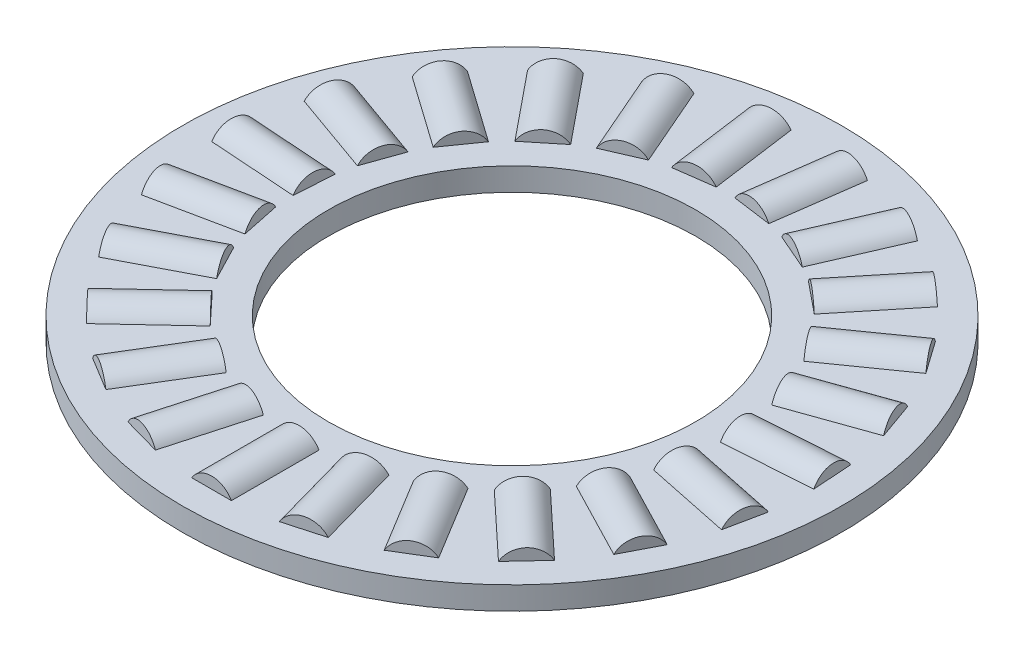
from build123d import *

# Parameters (mm, degrees)
SKETCH5_W         = 6.3246
SKETCH5_H         = 0.9921875
SKETCH3_W         = 3.79476
SKETCH3_H         = 0.9921875
SKETCH2_W         = 3.79476
SKETCH2_H         = 0.9921875
CIRPATTERN1_COUNT = 23
CIRPATTERN1_ANGLE = 344.347826087
CIRPATTERN2_COUNT = 23


with BuildPart() as part:
    # Sketch5 → Revolve3 (revolve)
    with BuildSketch(Plane(origin=(0, 0, 0), x_dir=(0, 0, -1), z_dir=(1, 0, 0))):
        with Locations((-11.1252, 0)):
            Rectangle(SKETCH5_W, SKETCH5_H)
    revolve(axis=Axis((0, -0.9921875, 0), (0, 1, 0)))

    # Sketch3 → Cut-Revolve1 (revolve, cut)
    with BuildSketch(Plane(origin=(0, 0, 0), x_dir=(0, 0, -1), z_dir=(1, 0, 0))):
        with Locations((-11.1252, 0.49609375)):
            Rectangle(SKETCH3_W, SKETCH3_H)
    cut_revolve1 = revolve(axis=Axis((0, 0, 13.02258), (0, 0, -1)), mode=Mode.SUBTRACT)

    # CirPattern2: Cut-Revolve1 ×23 about axis
    cirpattern2_axis = Axis((0, 0.9921875, 0), (0, -1, 0))
    for i in range(1, CIRPATTERN2_COUNT):
        add(cut_revolve1.rotate(cirpattern2_axis, i * 360 / CIRPATTERN2_COUNT), mode=Mode.SUBTRACT)


with BuildPart() as body_2:
    # Sketch2 → Revolve2 (revolve)
    with BuildSketch(Plane(origin=(0, 0, 0), x_dir=(0, 0, -1), z_dir=(1, 0, 0))):
        with Locations((-11.1252, 0.49609375)):
            Rectangle(SKETCH2_W, SKETCH2_H)
    revolve(axis=Axis((0, 0, 13.02258), (0, 0, -1)))


with BuildPart() as cirpattern1_1:
    # CirPattern1: pattern copy
    add(body_2.part.rotate(Axis((0, 0.9921875, 0), (0, -1, 0)), 1 * CIRPATTERN1_ANGLE / (CIRPATTERN1_COUNT - 1)))


with BuildPart() as cirpattern1_2:
    # CirPattern1: pattern copy
    add(body_2.part.rotate(Axis((0, 0.9921875, 0), (0, -1, 0)), 2 * CIRPATTERN1_ANGLE / (CIRPATTERN1_COUNT - 1)))


with BuildPart() as cirpattern1_3:
    # CirPattern1: pattern copy
    add(body_2.part.rotate(Axis((0, 0.9921875, 0), (0, -1, 0)), 3 * CIRPATTERN1_ANGLE / (CIRPATTERN1_COUNT - 1)))


with BuildPart() as cirpattern1_4:
    # CirPattern1: pattern copy
    add(body_2.part.rotate(Axis((0, 0.9921875, 0), (0, -1, 0)), 4 * CIRPATTERN1_ANGLE / (CIRPATTERN1_COUNT - 1)))


with BuildPart() as cirpattern1_5:
    # CirPattern1: pattern copy
    add(body_2.part.rotate(Axis((0, 0.9921875, 0), (0, -1, 0)), 5 * CIRPATTERN1_ANGLE / (CIRPATTERN1_COUNT - 1)))


with BuildPart() as cirpattern1_6:
    # CirPattern1: pattern copy
    add(body_2.part.rotate(Axis((0, 0.9921875, 0), (0, -1, 0)), 6 * CIRPATTERN1_ANGLE / (CIRPATTERN1_COUNT - 1)))


with BuildPart() as cirpattern1_7:
    # CirPattern1: pattern copy
    add(body_2.part.rotate(Axis((0, 0.9921875, 0), (0, -1, 0)), 7 * CIRPATTERN1_ANGLE / (CIRPATTERN1_COUNT - 1)))


with BuildPart() as cirpattern1_8:
    # CirPattern1: pattern copy
    add(body_2.part.rotate(Axis((0, 0.9921875, 0), (0, -1, 0)), 8 * CIRPATTERN1_ANGLE / (CIRPATTERN1_COUNT - 1)))


with BuildPart() as cirpattern1_9:
    # CirPattern1: pattern copy
    add(body_2.part.rotate(Axis((0, 0.9921875, 0), (0, -1, 0)), 9 * CIRPATTERN1_ANGLE / (CIRPATTERN1_COUNT - 1)))


with BuildPart() as cirpattern1_10:
    # CirPattern1: pattern copy
    add(body_2.part.rotate(Axis((0, 0.9921875, 0), (0, -1, 0)), 10 * CIRPATTERN1_ANGLE / (CIRPATTERN1_COUNT - 1)))


with BuildPart() as cirpattern1_11:
    # CirPattern1: pattern copy
    add(body_2.part.rotate(Axis((0, 0.9921875, 0), (0, -1, 0)), 11 * CIRPATTERN1_ANGLE / (CIRPATTERN1_COUNT - 1)))


with BuildPart() as cirpattern1_12:
    # CirPattern1: pattern copy
    add(body_2.part.rotate(Axis((0, 0.9921875, 0), (0, -1, 0)), 12 * CIRPATTERN1_ANGLE / (CIRPATTERN1_COUNT - 1)))


with BuildPart() as cirpattern1_13:
    # CirPattern1: pattern copy
    add(body_2.part.rotate(Axis((0, 0.9921875, 0), (0, -1, 0)), 13 * CIRPATTERN1_ANGLE / (CIRPATTERN1_COUNT - 1)))


with BuildPart() as cirpattern1_14:
    # CirPattern1: pattern copy
    add(body_2.part.rotate(Axis((0, 0.9921875, 0), (0, -1, 0)), 14 * CIRPATTERN1_ANGLE / (CIRPATTERN1_COUNT - 1)))


with BuildPart() as cirpattern1_15:
    # CirPattern1: pattern copy
    add(body_2.part.rotate(Axis((0, 0.9921875, 0), (0, -1, 0)), 15 * CIRPATTERN1_ANGLE / (CIRPATTERN1_COUNT - 1)))


with BuildPart() as cirpattern1_16:
    # CirPattern1: pattern copy
    add(body_2.part.rotate(Axis((0, 0.9921875, 0), (0, -1, 0)), 16 * CIRPATTERN1_ANGLE / (CIRPATTERN1_COUNT - 1)))


with BuildPart() as cirpattern1_17:
    # CirPattern1: pattern copy
    add(body_2.part.rotate(Axis((0, 0.9921875, 0), (0, -1, 0)), 17 * CIRPATTERN1_ANGLE / (CIRPATTERN1_COUNT - 1)))


with BuildPart() as cirpattern1_18:
    # CirPattern1: pattern copy
    add(body_2.part.rotate(Axis((0, 0.9921875, 0), (0, -1, 0)), 18 * CIRPATTERN1_ANGLE / (CIRPATTERN1_COUNT - 1)))


with BuildPart() as cirpattern1_19:
    # CirPattern1: pattern copy
    add(body_2.part.rotate(Axis((0, 0.9921875, 0), (0, -1, 0)), 19 * CIRPATTERN1_ANGLE / (CIRPATTERN1_COUNT - 1)))


with BuildPart() as cirpattern1_20:
    # CirPattern1: pattern copy
    add(body_2.part.rotate(Axis((0, 0.9921875, 0), (0, -1, 0)), 20 * CIRPATTERN1_ANGLE / (CIRPATTERN1_COUNT - 1)))


with BuildPart() as cirpattern1_21:
    # CirPattern1: pattern copy
    add(body_2.part.rotate(Axis((0, 0.9921875, 0), (0, -1, 0)), 21 * CIRPATTERN1_ANGLE / (CIRPATTERN1_COUNT - 1)))


with BuildPart() as cirpattern1_22:
    # CirPattern1: pattern copy
    add(body_2.part.rotate(Axis((0, 0.9921875, 0), (0, -1, 0)), 22 * CIRPATTERN1_ANGLE / (CIRPATTERN1_COUNT - 1)))


solid = Compound([part.part, body_2.part, cirpattern1_1.part, cirpattern1_2.part, cirpattern1_3.part, cirpattern1_4.part, cirpattern1_5.part, cirpattern1_6.part, cirpattern1_7.part, cirpattern1_8.part, cirpattern1_9.part, cirpattern1_10.part, cirpattern1_11.part, cirpattern1_12.part, cirpattern1_13.part, cirpattern1_14.part, cirpattern1_15.part, cirpattern1_16.part, cirpattern1_17.part, cirpattern1_18.part, cirpattern1_19.part, cirpattern1_20.part, cirpattern1_21.part, cirpattern1_22.part])
